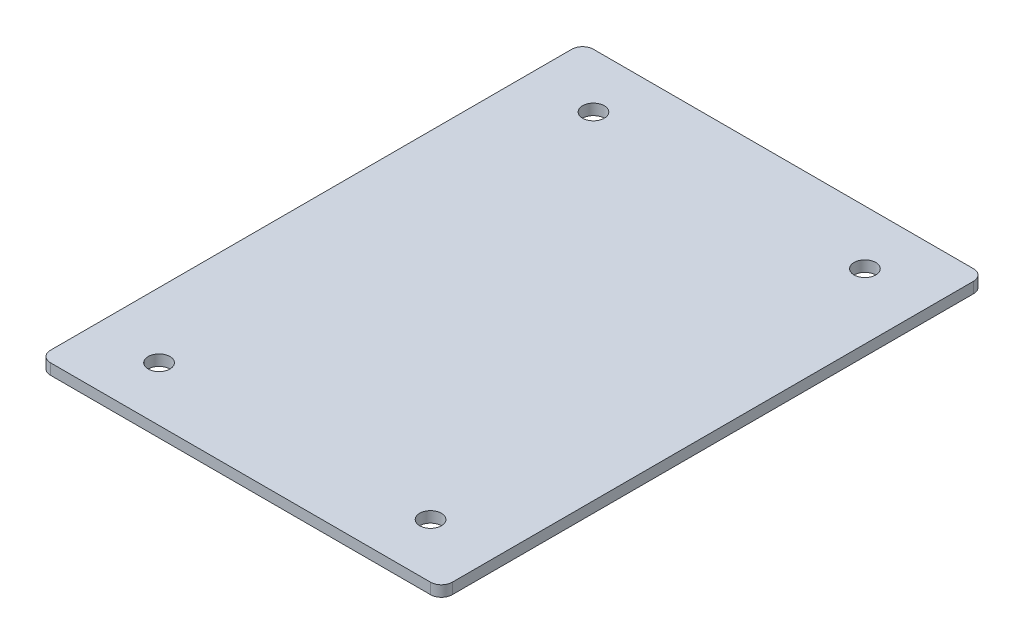
from build123d import *

# Parameters (mm, degrees)
SKETCH1_W           = 74
SKETCH1_H           = 100
BOSS_EXTRUDE1_DEPTH = 2
FILLET1_R           = 2
SKETCH2_R           = 2
CUT_EXTRUDE1_DEPTH  = 3


with BuildPart() as part:
    # Sketch1 → Boss-Extrude1 (new body)
    with BuildSketch(Plane(origin=(0, 0, 0), x_dir=(1, 0, 0), z_dir=(0, 1, 0))):
        with Locations((37, 50)):
            Rectangle(SKETCH1_W, SKETCH1_H)
    extrude(amount=BOSS_EXTRUDE1_DEPTH)

    # Fillet1
    fillet1_edges = [part.edges().sort_by_distance(p)[0] for p in [
        (0, 1, -100),
        (74, 1, -100),
        (74, 1, 0),
        (0, 1, 0),
    ]]
    fillet(fillet1_edges, radius=FILLET1_R)

    # Sketch2 → Cut-Extrude1 (cut, through all)
    with BuildSketch(Plane(origin=(0, 2, 0), x_dir=(1, 0, 0), z_dir=(0, 1, 0))):
        with Locations((12, 90)):
            Circle(SKETCH2_R)
        with Locations((62, 90)):
            Circle(SKETCH2_R)
        with Locations((62, 10)):
            Circle(SKETCH2_R)
        with Locations((12, 10)):
            Circle(SKETCH2_R)
    extrude(amount=-CUT_EXTRUDE1_DEPTH, mode=Mode.SUBTRACT)


solid = part.part
